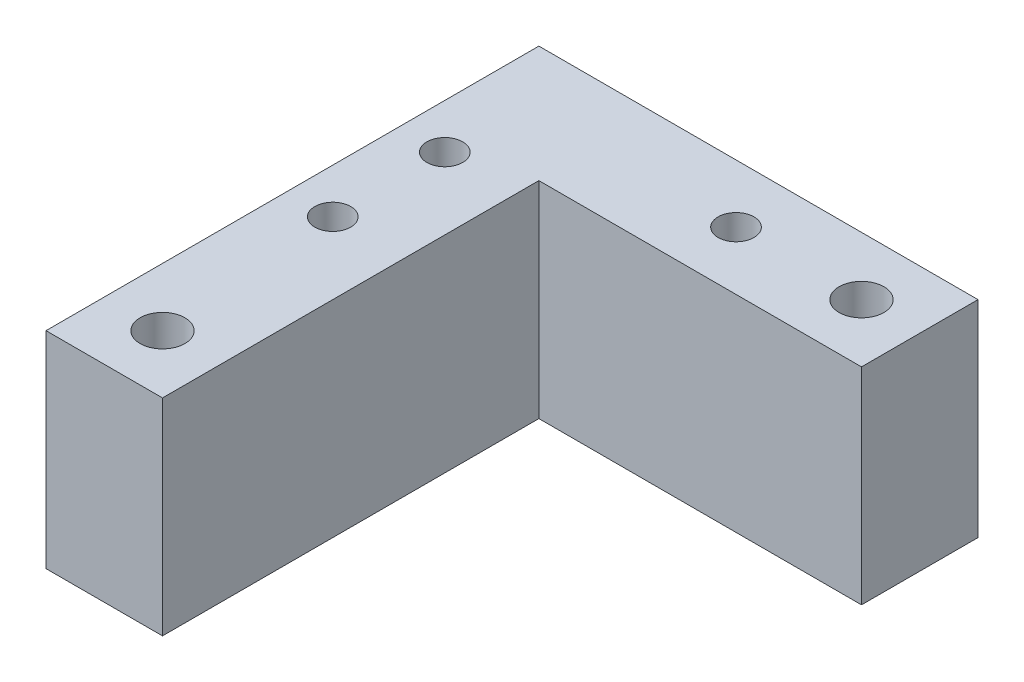
from build123d import *

# Parameters (mm, degrees)
SKETCH1_R           = 2
BOSS_EXTRUDE1_DEPTH = 23
SKETCH2_W           = 15
SKETCH2_H           = 13
SKETCH2_W_2         = 13
SKETCH2_H_2         = 15
BOSS_EXTRUDE2_DEPTH = 23
SKETCH3_R           = 2.5
CUT_EXTRUDE1_DEPTH  = 23
SKETCH4_R           = 4
CUT_EXTRUDE2_DEPTH  = 4.4


with BuildPart() as part:
    # Sketch1 → Boss-Extrude1 (new body)
    with BuildSketch(Plane(origin=(0, 0, 0), x_dir=(1, 0, 0), z_dir=(0, 1, 0))):
        Polygon((-23.607929515, -18.04845815), (-23.607929515, 21.95154185), (10.392070485, 21.95154185), (10.392070485, 8.95154185), (-10.607929515, 8.95154185), (-10.607929515, -18.04845815), align=None)
        with Locations(Location((-18.607929515, -6.04845815, 0), (0, 0, 270))):  # turned: the seam where the file's is
            Circle(SKETCH1_R, mode=Mode.SUBTRACT)
        with Locations(Location((-18.607929515, 6.45154185, 0), (0, 0, 270))):  # turned: the seam where the file's is
            Circle(SKETCH1_R, mode=Mode.SUBTRACT)
        with Locations(Location((4.892070485, 15.45154185, 0), (0, 0, 270))):  # turned: the seam where the file's is
            Circle(SKETCH1_R, mode=Mode.SUBTRACT)
    extrude(amount=BOSS_EXTRUDE1_DEPTH)

    # Sketch2 → Boss-Extrude2 (add)
    with BuildSketch(Plane(origin=(0, 23, 0), x_dir=(1, 0, 0), z_dir=(0, 1, 0))):
        with Locations((17.892070485, 15.45154185)):
            Rectangle(SKETCH2_W, SKETCH2_H)
        with Locations((-17.107929515, -25.54845815)):
            Rectangle(SKETCH2_W_2, SKETCH2_H_2)
    extrude(amount=-BOSS_EXTRUDE2_DEPTH)

    # Sketch3 → Cut-Extrude1 (cut)
    with BuildSketch(Plane(origin=(0, 23, 0), x_dir=(1, 0, 0), z_dir=(0, 1, 0))):
        with Locations(Location((18.892070485, 15.45154185, 0), (0, 0, 270))):  # turned: the seam where the file's is
            Circle(SKETCH3_R)
        with Locations(Location((-17.107929515, -26.54845815, 0), (0, 0, 270))):  # turned: the seam where the file's is
            Circle(SKETCH3_R)
    extrude(amount=-CUT_EXTRUDE1_DEPTH, mode=Mode.SUBTRACT)

    # Sketch4 → Cut-Extrude2 (cut)
    with BuildSketch(Plane.XZ):
        with Locations(Location((-18.607929515, 6.04845815, 0), (0, 0, 270))):  # turned: the seam where the file's is
            Circle(SKETCH4_R)
        with Locations(Location((-18.607929515, -6.45154185, 0), (0, 0, 270))):  # turned: the seam where the file's is
            Circle(SKETCH4_R)
        with Locations(Location((4.892070485, -15.45154185, 0), (0, 0, 270))):  # turned: the seam where the file's is
            Circle(SKETCH4_R)
    extrude(amount=-CUT_EXTRUDE2_DEPTH, mode=Mode.SUBTRACT)


solid = part.part
